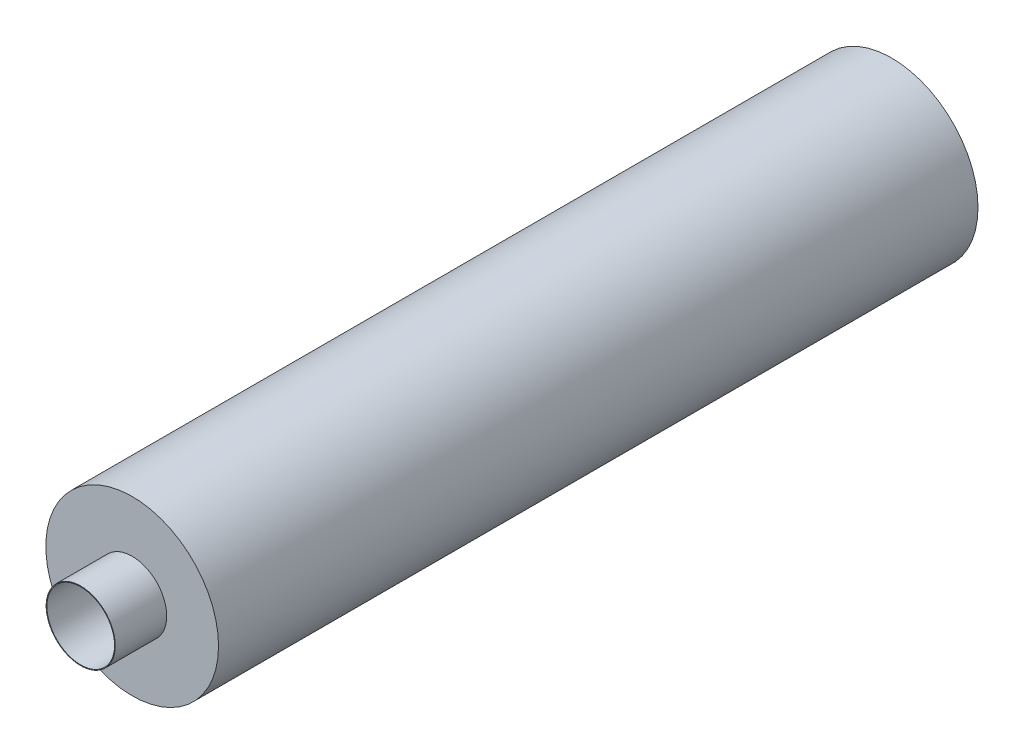
from build123d import *

# Parameters (mm, degrees)
SKETCH1_R           = 250
BOSS_EXTRUDE1_DEPTH = 2198
SHELL2_T            = -2
SKETCH2_R           = 100
SKETCH2_R_2         = 98
EXTRUDE_THIN1_DEPTH = 150
SKETCH3_R           = 250
SKETCH3_R_2         = 98
BOSS_EXTRUDE2_DEPTH = 1


with BuildPart() as part:
    # Sketch1 → Boss-Extrude1 (new body)
    with BuildSketch(Plane.XY):
        Circle(SKETCH1_R)
    extrude(amount=BOSS_EXTRUDE1_DEPTH)

    # Shell2
    shell2_openings = [part.faces().sort_by_distance(p)[0] for p in [
        (0, 0, 2198),
    ]]
    offset(amount=SHELL2_T, openings=shell2_openings, kind=Kind.INTERSECTION)



with BuildPart() as body_2:
    # Sketch2 → Extrude-Thin1 (new body)
    with BuildSketch(Plane.XY.offset(2198)):
        Circle(SKETCH2_R)
        Circle(SKETCH2_R_2, mode=Mode.SUBTRACT)
    extrude(amount=EXTRUDE_THIN1_DEPTH)


with BuildPart() as part_1:
    add(part.part)

    add(body_2.part)  # Boss-Extrude2 merges body 2
    # Sketch3 → Boss-Extrude2 (add)
    with BuildSketch(Plane.XY.offset(2198)):
        Circle(SKETCH3_R)
        Circle(SKETCH3_R_2, mode=Mode.SUBTRACT)
    extrude(amount=BOSS_EXTRUDE2_DEPTH)


solid = part_1.part
